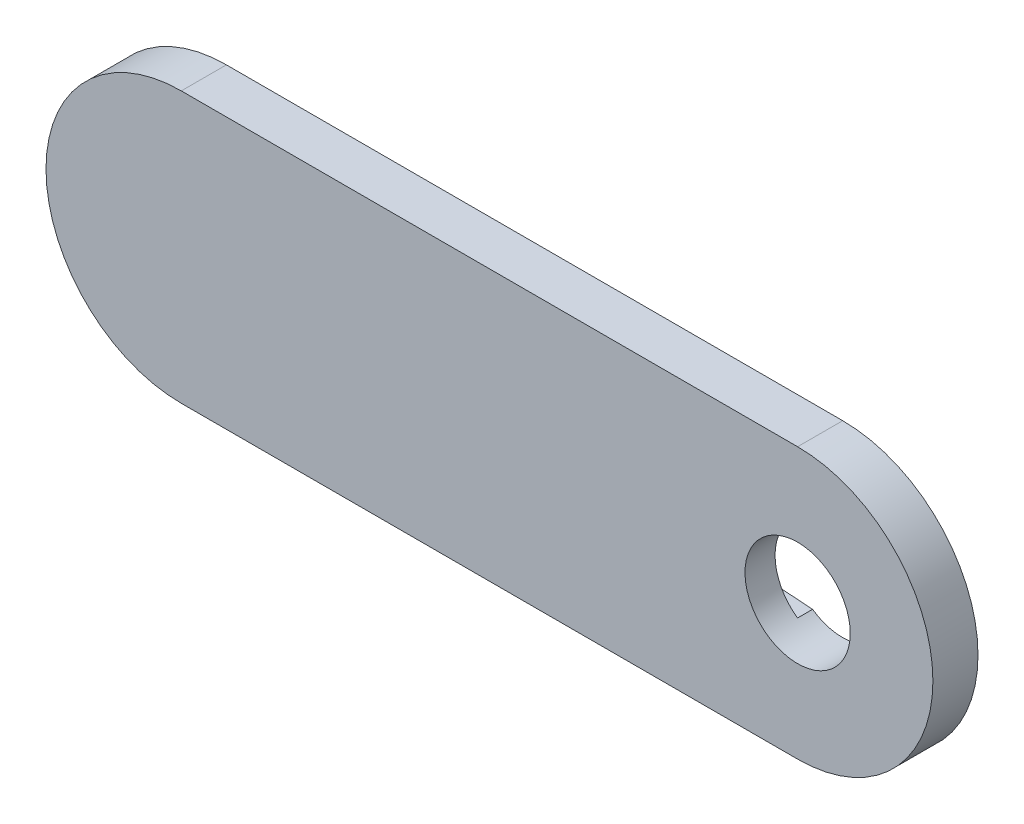
from build123d import *

# Parameters (mm, degrees)
CORTE_EXTERIOR_R        = 3.500001168
SALIENTE_EXTRUIR1_DEPTH = 3
CORTAR_EXTRUIR1_DEPTH   = 1


with BuildPart() as part:
    # Corte exterior → Saliente-Extruir1 (new body)
    with BuildSketch(Plane.XY):
        with BuildLine():
            Line((31.389373952, 4.705371802), (72.389373952, 4.705371802))
            ThreePointArc((72.389373952, 4.705371802), (81.389373952, 13.705371802), (72.389373952, 22.705371802))
            Line((72.389373952, 22.705371802), (31.389373952, 22.705371802))
            ThreePointArc((31.389373952, 22.705371802), (22.389373952, 13.705371802), (31.389373952, 4.705371802))
        make_face()
        with Locations((72.389373952, 13.705371802)):
            Circle(CORTE_EXTERIOR_R, mode=Mode.SUBTRACT)
    extrude(amount=SALIENTE_EXTRUIR1_DEPTH)

    # Grabado Superficie → Cortar-Extruir1 (cut)
    with BuildSketch(Plane.XY):
        with BuildLine():
            Line((70.385171574, 16.57472382), (57.998553299, 15.700408028))
            ThreePointArc((57.998553299, 15.700408028), (56.139373952, 13.705371802), (57.998553299, 11.710335575))
            Line((57.998553299, 11.710335575), (70.385171574, 10.836019783))
            ThreePointArc((70.385171574, 10.836019783), (68.889372784, 13.705371802), (70.385171574, 16.57472382))
        make_face()
    extrude(amount=CORTAR_EXTRUIR1_DEPTH, mode=Mode.SUBTRACT)


solid = part.part
